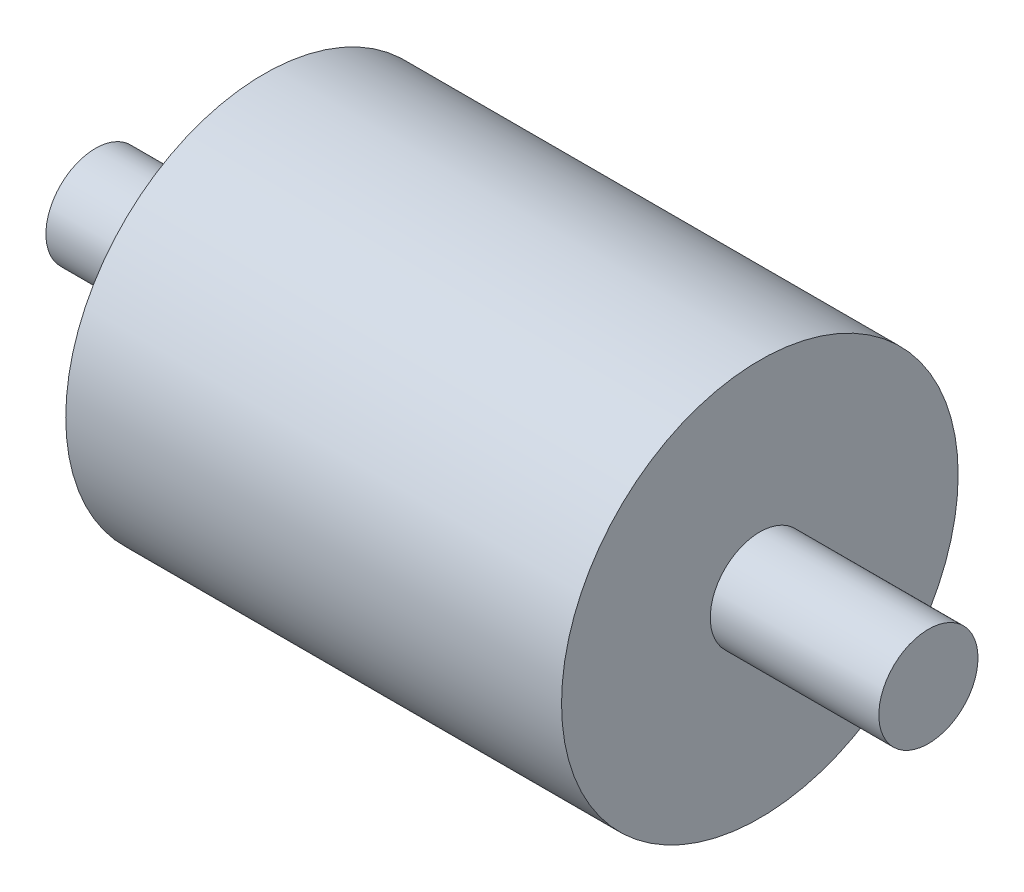
from build123d import *

# Parameters (mm, degrees)
SKETCH_1_R      = 20
EXTRUDE_1_DEPTH = 25
SKETCH_2_R      = 5
EXTRUDE_2_DEPTH = 42


with BuildPart() as part:
    # 草图1 → 凸台-拉伸1 (new body, symmetric)
    with BuildSketch(Plane(origin=(0, 0, 0), x_dir=(0, 0, -1), z_dir=(1, 0, 0))):
        Circle(SKETCH_1_R)
    extrude(amount=EXTRUDE_1_DEPTH, both=True)

    # 草图2 → 凸台-拉伸2 (add, symmetric)
    with BuildSketch(Plane(origin=(0, 0, 0), x_dir=(0, 0, -1), z_dir=(1, 0, 0))):
        Circle(SKETCH_2_R)
    extrude(amount=EXTRUDE_2_DEPTH, both=True)


solid = part.part
